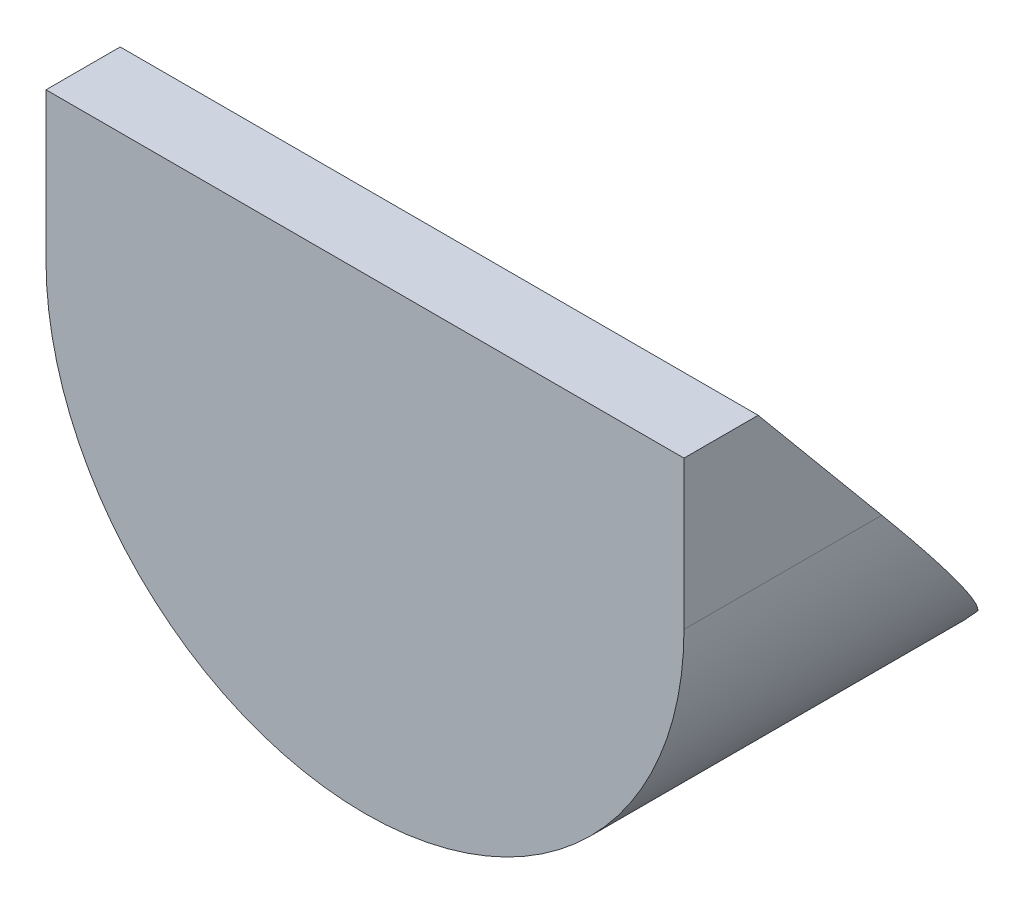
from build123d import *

# Parameters (mm, degrees)
EXTRUDE_1_DEPTH          = 50
CUT_EXTRUDE_1_DEPTH      = 87
CUT_EXTRUDE_1_DEPTH_BACK = 1
SKETCH_3_R               = 2
CUT_EXTRUDE_2_DEPTH      = 20


with BuildPart() as part:
    # Эскиз1 → Бобышка-Вытянуть1 (new body)
    with BuildSketch(Plane.XY):
        with BuildLine():
            Line((0, 20), (0, 0))
            ThreePointArc((0, 0), (43, -43), (86, 0))
            Line((86, 0), (86, 20))
            Line((86, 20), (0, 20))
        make_face()
    extrude(amount=EXTRUDE_1_DEPTH)

    # Эскиз2 → Вырез-Вытянуть1 (cut, two sides)
    with BuildSketch(Plane(origin=(0, 0, 0), x_dir=(0, 0, -1), z_dir=(1, 0, 0))) as cut_extrude_1_sk:
        Polygon((-40, 20), (0, -28), (0, 20), align=None)
    extrude(amount=CUT_EXTRUDE_1_DEPTH, mode=Mode.SUBTRACT)
    extrude(cut_extrude_1_sk.sketch, amount=-CUT_EXTRUDE_1_DEPTH_BACK, mode=Mode.SUBTRACT)

    # Эскиз3 → Вырез-Вытянуть2 (cut)
    with BuildSketch(Plane(origin=(0, -43, 0), x_dir=(-1, 0, 0), z_dir=(0, -1, 0))):
        with Locations((-43, -38)):
            Circle(SKETCH_3_R)
    extrude(amount=-CUT_EXTRUDE_2_DEPTH, mode=Mode.SUBTRACT)


solid = part.part
